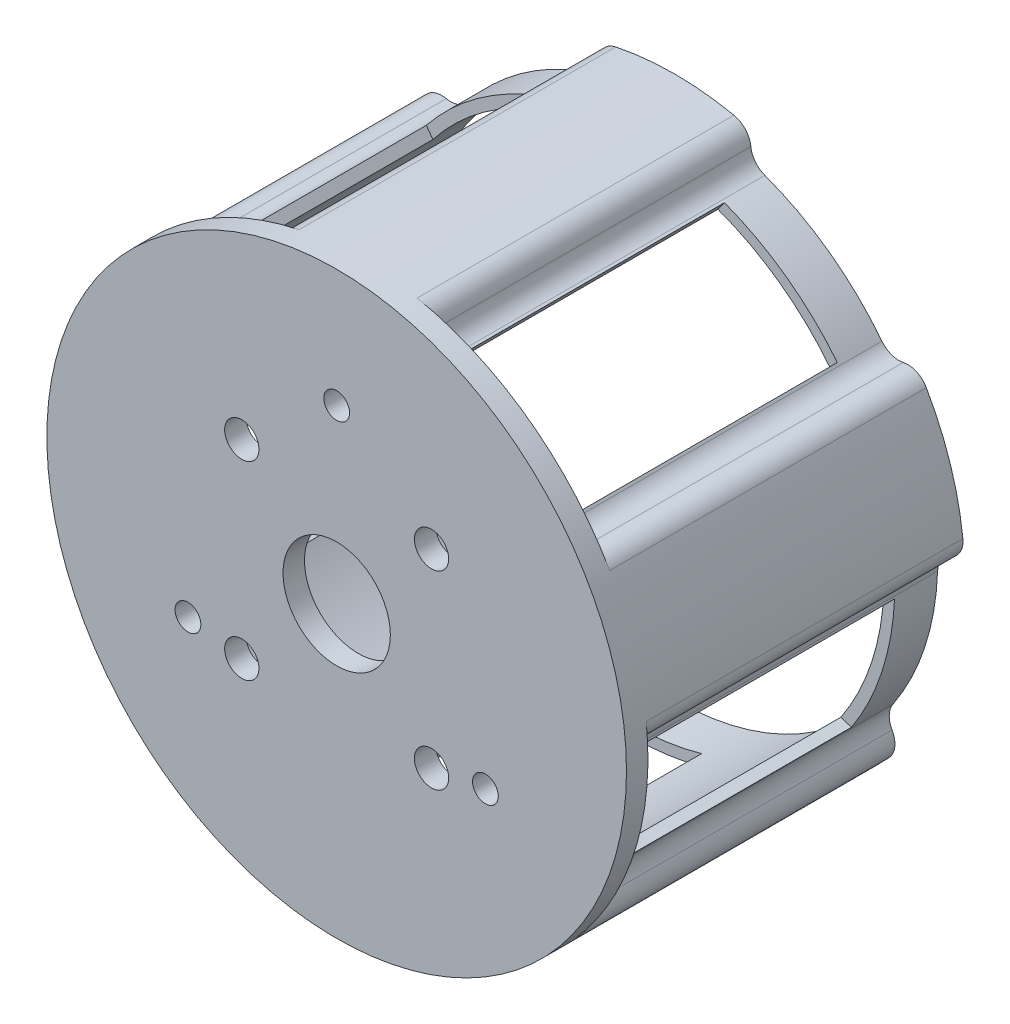
from build123d import *

# Parameters (mm, degrees)
SKETCH_1_R          = 27
SKETCH_1_R_2        = 23.5
SKETCH_1_R_3        = 1
EXTRUDE_1_DEPTH     = 27.5
CUT_EXTRUDE_1_DEPTH = 26
SKETCH_3_R          = 27
SKETCH_3_R_2        = 1.595744681
EXTRUDE_2_DEPTH     = 1.5
SKETCH_4_R          = 5
CUT_EXTRUDE_2_DEPTH = 1.5
SKETCH_5_R          = 1.2
CUT_EXTRUDE_3_DEPTH = 1.5
SKETCH_6_R          = 27
SKETCH_6_R_2        = 23.5
SKETCH_6_R_3        = 1
EXTRUDE_3_DEPTH     = 2
SKETCH_7_R          = 27
SKETCH_7_R_2        = 1.2
SKETCH_7_R_3        = 1.595744681
SKETCH_7_R_4        = 5
EXTRUDE_4_DEPTH     = 0.5
FILLET_1_R          = 1
FILLET_2_R          = 1
FILLET_3_R          = 1
CUT_EXTRUDE_4_DEPTH = 0.8
FILLET_4_R          = 1
CUT_EXTRUDE_5_DEPTH = 29.5
FILLET_5_R          = 2
SKETCH_10_R         = 23.5
SKETCH_10_R_2       = 1
EXTRUDE_6_DEPTH     = 4


with BuildPart() as part:
    # 草图1 → 凸台-拉伸1 (new body)
    with BuildSketch(Plane.XY):
        Circle(SKETCH_1_R)
        Circle(SKETCH_1_R_2, mode=Mode.SUBTRACT)
        with Locations((0, 25)):
            Circle(SKETCH_1_R_3, mode=Mode.SUBTRACT)
        with Locations((23.776412907, 7.725424859)):
            Circle(SKETCH_1_R_3, mode=Mode.SUBTRACT)
        with Locations((14.694631307, -20.225424859)):
            Circle(SKETCH_1_R_3, mode=Mode.SUBTRACT)
        with Locations((-14.694631307, -20.225424859)):
            Circle(SKETCH_1_R_3, mode=Mode.SUBTRACT)
        with Locations((-23.776412907, 7.725424859)):
            Circle(SKETCH_1_R_3, mode=Mode.SUBTRACT)
    extrude(amount=EXTRUDE_1_DEPTH)

    # 草图2 → 切除-拉伸1 (cut)
    with BuildSketch(Plane.XY.offset(27.5)):
        with BuildLine():
            Line((-19.469269636, -13.160453634), (-22.914696108, -14.279940556))
            ThreePointArc((-22.914696108, -14.279940556), (-25.67852594, -8.343458848), (-26.931917035, -1.916205844))
            Line((-26.931917035, -1.916205844), (-23.486490563, -0.796718922))
            ThreePointArc((-23.486490563, -0.796718922), (-22.349828133, -7.261899368), (-19.469269636, -13.160453634))
        make_face()
        with BuildLine():
            Line((6.5, -22.583179581), (6.5, -26.205915363))
            ThreePointArc((6.5, -26.205915363), (0, -27), (-6.5, -26.205915363))
            Line((-6.5, -26.205915363), (-6.5, -22.583179581))
            ThreePointArc((-6.5, -22.583179581), (0, -23.5), (6.5, -22.583179581))
        make_face()
        with BuildLine():
            Line((-18.532670371, 14.449571928), (-20.662061036, 17.380426742))
            ThreePointArc((-20.662061036, 17.380426742), (-15.870201812, 21.843458848), (-10.14484011, 25.021635022))
            Line((-10.14484011, 25.021635022), (-8.015449444, 22.090780208))
            ThreePointArc((-8.015449444, 22.090780208), (-13.812953429, 19.011899368), (-18.532670371, 14.449571928))
        make_face()
        with BuildLine():
            Line((8.015449444, 22.090780208), (10.14484011, 25.021635022))
            ThreePointArc((10.14484011, 25.021635022), (15.870201812, 21.843458848), (20.662061036, 17.380426742))
            Line((20.662061036, 17.380426742), (18.532670371, 14.449571928))
            ThreePointArc((18.532670371, 14.449571928), (13.812953429, 19.011899368), (8.015449444, 22.090780208))
        make_face()
        with BuildLine():
            Line((23.486490563, -0.796718922), (26.931917035, -1.916205844))
            ThreePointArc((26.931917035, -1.916205844), (25.67852594, -8.343458848), (22.914696108, -14.279940556))
            Line((22.914696108, -14.279940556), (19.469269636, -13.160453634))
            ThreePointArc((19.469269636, -13.160453634), (22.349828133, -7.261899368), (23.486490563, -0.796718922))
        make_face()
    extrude(amount=-CUT_EXTRUDE_1_DEPTH, mode=Mode.SUBTRACT)

    # 草图3 → 凸台-拉伸2 (add)
    with BuildSketch(Plane.XY.offset(27.5)):
        Circle(SKETCH_3_R)
        with Locations((8.838834765, 8.838834765)):
            Circle(SKETCH_3_R_2, mode=Mode.SUBTRACT)
        with Locations((-8.838834765, 8.838834765)):
            Circle(SKETCH_3_R_2, mode=Mode.SUBTRACT)
        with Locations((-8.838834765, -8.838834765)):
            Circle(SKETCH_3_R_2, mode=Mode.SUBTRACT)
        with Locations((8.838834765, -8.838834765)):
            Circle(SKETCH_3_R_2, mode=Mode.SUBTRACT)
    extrude(amount=EXTRUDE_2_DEPTH)

    # 草图4 → 切除-拉伸2 (cut)
    with BuildSketch(Plane.XY.offset(29)):
        Circle(SKETCH_4_R)
    extrude(amount=-CUT_EXTRUDE_2_DEPTH, mode=Mode.SUBTRACT)

    # 草图5 → 切除-拉伸3 (cut)
    with BuildSketch(Plane.XY.offset(29)):
        with Locations((0, 16)):
            Circle(SKETCH_5_R)
        with Locations((13.856406461, -8)):
            Circle(SKETCH_5_R)
        with Locations((-13.856406461, -8)):
            Circle(SKETCH_5_R)
    extrude(amount=-CUT_EXTRUDE_3_DEPTH, mode=Mode.SUBTRACT)

    # 草图6 → 凸台-拉伸3 (add)
    with BuildSketch(Plane(origin=(0, 0, 0), x_dir=(-1, 0, 0), z_dir=(0, 0, -1))):
        Circle(SKETCH_6_R)
        Circle(SKETCH_6_R_2, mode=Mode.SUBTRACT)
        with Locations((14.694631307, -20.225424859)):
            Circle(SKETCH_6_R_3, mode=Mode.SUBTRACT)
        with Locations((-14.694631307, -20.225424859)):
            Circle(SKETCH_6_R_3, mode=Mode.SUBTRACT)
        with Locations((-23.776412907, 7.725424859)):
            Circle(SKETCH_6_R_3, mode=Mode.SUBTRACT)
        with Locations((0, 25)):
            Circle(SKETCH_6_R_3, mode=Mode.SUBTRACT)
        with Locations((23.776412907, 7.725424859)):
            Circle(SKETCH_6_R_3, mode=Mode.SUBTRACT)
    extrude(amount=EXTRUDE_3_DEPTH)

    # 草图7 → 凸台-拉伸4 (add)
    with BuildSketch(Plane.XY.offset(29)):
        Circle(SKETCH_7_R)
        with Locations((0, 16)):
            Circle(SKETCH_7_R_2, mode=Mode.SUBTRACT)
        with Locations((-8.838834765, 8.838834765)):
            Circle(SKETCH_7_R_3, mode=Mode.SUBTRACT)
        with Locations((-13.856406461, -8)):
            Circle(SKETCH_7_R_2, mode=Mode.SUBTRACT)
        with Locations((-8.838834765, -8.838834765)):
            Circle(SKETCH_7_R_3, mode=Mode.SUBTRACT)
        with Locations((13.856406461, -8)):
            Circle(SKETCH_7_R_2, mode=Mode.SUBTRACT)
        with Locations((8.838834765, -8.838834765)):
            Circle(SKETCH_7_R_3, mode=Mode.SUBTRACT)
        Circle(SKETCH_7_R_4, mode=Mode.SUBTRACT)
        with Locations((8.838834765, 8.838834765)):
            Circle(SKETCH_7_R_3, mode=Mode.SUBTRACT)
    extrude(amount=EXTRUDE_4_DEPTH)

    # 圆角1
    fillet_1_edges = [part.edges().sort_by_distance(p)[0] for p in [
        (-21.191982872, -13.720197095, 27.5),
    ]]
    fillet(fillet_1_edges, radius=FILLET_1_R)

    # 圆角2
    fillet_2_edges = [part.edges().sort_by_distance(p)[0] for p in [
        (-25.209203799, -1.356462383, 27.5),
    ]]
    fillet(fillet_2_edges, radius=FILLET_2_R)

    # 圆角3
    fillet_3_edges = [part.edges().sort_by_distance(p)[0] for p in [
        (6.5, -24.394547472, 27.5),
        (-6.5, -24.394547472, 27.5),
        (-19.597365704, 15.914999335, 27.5),
        (-9.080144777, 23.556207615, 27.5),
        (9.080144777, 23.556207615, 27.5),
        (19.597365704, 15.914999335, 27.5),
        (25.209203799, -1.356462383, 27.5),
        (21.191982872, -13.720197095, 27.5),
    ]]
    fillet(fillet_3_edges, radius=FILLET_3_R)

    # 草图8 → 切除-拉伸4 (cut)
    with BuildSketch(Plane.XY.offset(1.5)):
        with BuildLine():
            Line((19.469269636, -13.160453634), (22.914696108, -14.279940556))
            ThreePointArc((22.914696108, -14.279940556), (25.67852594, -8.343458848), (26.931917035, -1.916205844))
            Line((26.931917035, -1.916205844), (23.486490563, -0.796718922))
            ThreePointArc((23.486490563, -0.796718922), (22.349828133, -7.261899368), (19.469269636, -13.160453634))
        make_face()
        with BuildLine():
            Line((10.14484011, 25.021635022), (8.015449444, 22.090780208))
            ThreePointArc((8.015449444, 22.090780208), (13.812953429, 19.011899368), (18.532670371, 14.449571928))
            Line((18.532670371, 14.449571928), (20.662061036, 17.380426742))
            ThreePointArc((20.662061036, 17.380426742), (15.870201812, 21.843458848), (10.14484011, 25.021635022))
        make_face()
        with BuildLine():
            Line((-6.5, -22.583179581), (-6.5, -26.205915363))
            ThreePointArc((-6.5, -26.205915363), (0, -27), (6.5, -26.205915363))
            Line((6.5, -26.205915363), (6.5, -22.583179581))
            ThreePointArc((6.5, -22.583179581), (0, -23.5), (-6.5, -22.583179581))
        make_face()
        with BuildLine():
            Line((-23.486490563, -0.796718922), (-26.931917035, -1.916205844))
            ThreePointArc((-26.931917035, -1.916205844), (-25.67852594, -8.343458848), (-22.914696108, -14.279940556))
            Line((-22.914696108, -14.279940556), (-19.469269636, -13.160453634))
            ThreePointArc((-19.469269636, -13.160453634), (-22.349828133, -7.261899368), (-23.486490563, -0.796718922))
        make_face()
        with BuildLine():
            Line((-8.015449444, 22.090780208), (-10.14484011, 25.021635022))
            ThreePointArc((-10.14484011, 25.021635022), (-15.870201812, 21.843458848), (-20.662061036, 17.380426742))
            Line((-20.662061036, 17.380426742), (-18.532670371, 14.449571928))
            ThreePointArc((-18.532670371, 14.449571928), (-13.812953429, 19.011899368), (-8.015449444, 22.090780208))
        make_face()
    extrude(amount=-CUT_EXTRUDE_4_DEPTH, mode=Mode.SUBTRACT)

    # 圆角4
    fillet_4_edges = [part.edges().sort_by_distance(p)[0] for p in [
        (-9.080144777, 23.556207615, 0.7),
        (-19.597365704, 15.914999335, 0.7),
        (-25.209203799, -1.356462383, 0.7),
        (-21.191982872, -13.720197095, 0.7),
        (-6.5, -24.394547472, 0.7),
        (6.5, -24.394547472, 0.7),
        (21.191982872, -13.720197095, 0.7),
        (25.209203799, -1.356462383, 0.7),
        (19.597365704, 15.914999335, 0.7),
        (9.080144777, 23.556207615, 0.7),
    ]]
    fillet(fillet_4_edges, radius=FILLET_4_R)

    # 草图9 → 切除-拉伸5 (cut)
    with BuildSketch(Plane(origin=(0, 0, -2), x_dir=(-1, 0, 0), z_dir=(0, 0, -1))):
        with BuildLine():
            Line((21.153306776, 14.336583011), (20.083521571, 14.032183056))
            ThreePointArc((20.083521571, 14.032183056), (14.929861697, 19.42547888), (8.392087366, 23.01788152))
            ThreePointArc((8.392087366, 23.01788152), (7.501479868, 23.665127017), (7.088344874, 24.685630779))
            ThreePointArc((7.088344874, 24.685630779), (6.582389612, 25.816434618), (5.507496749, 26.432318846))
            ThreePointArc((5.507496749, 26.432318846), (15.870201812, 21.843458848), (23.436718987, 13.405976395))
            ThreePointArc((23.436718987, 13.405976395), (22.455487368, 14.265032976), (21.153306776, 14.336583011))
        make_face()
        with BuildLine():
            ThreePointArc((-11.080868735, -24.621420513), (-9.849254476, -24.754965879), (-8.77525825, -24.137519397))
            ThreePointArc((-8.77525825, -24.137519397), (-7.841187958, -23.554749168), (-6.740229999, -23.554602513))
            ThreePointArc((-6.740229999, -23.554602513), (0, -24.5), (6.740229999, -23.554602513))
            ThreePointArc((6.740229999, -23.554602513), (7.841187958, -23.554749168), (8.77525825, -24.137519397))
            ThreePointArc((8.77525825, -24.137519397), (9.849254476, -24.754965879), (11.080868735, -24.621420513))
            ThreePointArc((11.080868735, -24.621420513), (0, -27), (-11.080868735, -24.621420513))
        make_face()
        with BuildLine():
            ThreePointArc((19.992185667, -18.146969781), (20.499784595, -17.016902801), (20.244441181, -15.804670237))
            ThreePointArc((20.244441181, -15.804670237), (19.97883735, -14.736230695), (20.318912593, -13.689112134))
            ThreePointArc((20.318912593, -13.689112134), (23.300884649, -7.570916362), (24.484603825, -0.86843281))
            ThreePointArc((24.484603825, -0.86843281), (24.824958021, 0.178595112), (25.667849039, 0.886862845))
            ThreePointArc((25.667849039, 0.886862845), (26.586958624, 1.717492498), (26.840539171, 2.930095053))
            ThreePointArc((26.840539171, 2.930095053), (25.67852594, -8.343458848), (19.992185667, -18.146969781))
        make_face()
        with BuildLine():
            ThreePointArc((-5.507496749, 26.432318846), (-6.582389612, 25.816434618), (-7.088344874, 24.685630779))
            ThreePointArc((-7.088344874, 24.685630779), (-7.501479868, 23.665127017), (-8.392087366, 23.01788152))
            ThreePointArc((-8.392087366, 23.01788152), (-14.400738681, 19.820916362), (-19.298008596, 15.094265938))
            ThreePointArc((-19.298008596, 15.094265938), (-20.188788497, 14.447257733), (-21.287010983, 14.36969601))
            ThreePointArc((-21.287010983, 14.36969601), (-22.518818117, 14.237941564), (-23.436718987, 13.405976395))
            ThreePointArc((-23.436718987, 13.405976395), (-15.870201812, 21.843458848), (-5.507496749, 26.432318846))
        make_face()
        with BuildLine():
            ThreePointArc((-26.840539171, 2.930095053), (-26.586958624, 1.717492498), (-25.667849039, 0.886862845))
            ThreePointArc((-25.667849039, 0.886862845), (-24.824958021, 0.178595112), (-24.484603825, -0.86843281))
            ThreePointArc((-24.484603825, -0.86843281), (-23.300884649, -7.570916362), (-20.318912593, -13.689112134))
            ThreePointArc((-20.318912593, -13.689112134), (-19.97883735, -14.736230694), (-20.244441181, -15.804670237))
            ThreePointArc((-20.244441181, -15.804670237), (-20.499784595, -17.016902801), (-19.992185667, -18.146969781))
            ThreePointArc((-19.992185667, -18.146969781), (-25.67852594, -8.343458848), (-26.840539171, 2.930095053))
        make_face()
    extrude(amount=-CUT_EXTRUDE_5_DEPTH, mode=Mode.SUBTRACT)

    # 圆角5
    fillet_5_edges = [part.edges().sort_by_distance(p)[0] for p in [
        (-20.083521571, 14.032183056, 12.75),
    ]]
    fillet(fillet_5_edges, radius=FILLET_5_R)

    # 草图10 → 凸台-拉伸6 (add)
    with BuildSketch(Plane(origin=(0, 0, -2), x_dir=(-1, 0, 0), z_dir=(0, 0, -1))):
        with BuildLine():
            ThreePointArc((-21.287010983, 14.36969601), (-22.518818117, 14.237941564), (-23.436718987, 13.405976395))
            ThreePointArc((-23.436718987, 13.405976395), (-25.67852594, 8.343458848), (-26.840539171, 2.930095053))
            ThreePointArc((-26.840539171, 2.930095053), (-26.586958624, 1.717492498), (-25.667849039, 0.886862845))
            ThreePointArc((-25.667849039, 0.886862845), (-24.824958021, 0.178595112), (-24.484603825, -0.86843281))
            ThreePointArc((-24.484603825, -0.86843281), (-23.300884649, -7.570916362), (-20.318912593, -13.689112134))
            ThreePointArc((-20.318912593, -13.689112134), (-19.97883735, -14.736230694), (-20.244441181, -15.804670237))
            ThreePointArc((-20.244441181, -15.804670237), (-20.499784595, -17.016902801), (-19.992185667, -18.146969781))
            ThreePointArc((-19.992185667, -18.146969781), (-15.870201812, -21.843458848), (-11.080868735, -24.621420513))
            ThreePointArc((-11.080868735, -24.621420513), (-9.849254476, -24.754965879), (-8.77525825, -24.137519397))
            ThreePointArc((-8.77525825, -24.137519397), (-7.841187958, -23.554749168), (-6.740229999, -23.554602513))
            ThreePointArc((-6.740229999, -23.554602513), (0, -24.5), (6.740229999, -23.554602513))
            ThreePointArc((6.740229999, -23.554602513), (7.841187958, -23.554749168), (8.77525825, -24.137519397))
            ThreePointArc((8.77525825, -24.137519397), (9.849254476, -24.754965879), (11.080868735, -24.621420513))
            ThreePointArc((11.080868735, -24.621420513), (15.870201812, -21.843458848), (19.992185667, -18.146969781))
            ThreePointArc((19.992185667, -18.146969781), (20.499784595, -17.016902801), (20.244441181, -15.804670237))
            ThreePointArc((20.244441181, -15.804670237), (19.97883735, -14.736230695), (20.318912593, -13.689112134))
            ThreePointArc((20.318912593, -13.689112134), (23.300884649, -7.570916362), (24.484603825, -0.86843281))
            ThreePointArc((24.484603825, -0.86843281), (24.824958021, 0.178595112), (25.667849039, 0.886862845))
            ThreePointArc((25.667849039, 0.886862845), (26.586958624, 1.717492498), (26.840539171, 2.930095053))
            ThreePointArc((26.840539171, 2.930095053), (25.67852594, 8.343458848), (23.436718987, 13.405976395))
            ThreePointArc((23.436718987, 13.405976395), (22.518818117, 14.237941564), (21.287010983, 14.36969601))
            ThreePointArc((21.287010983, 14.36969601), (20.188788497, 14.447257733), (19.298008596, 15.094265938))
            ThreePointArc((19.298008596, 15.094265938), (14.400738681, 19.820916362), (8.392087366, 23.01788152))
            ThreePointArc((8.392087366, 23.01788152), (7.501479868, 23.665127017), (7.088344874, 24.685630779))
            ThreePointArc((7.088344874, 24.685630779), (6.582389612, 25.816434618), (5.507496749, 26.432318846))
            ThreePointArc((5.507496749, 26.432318846), (0, 27), (-5.507496749, 26.432318846))
            ThreePointArc((-5.507496749, 26.432318846), (-6.582389612, 25.816434618), (-7.088344874, 24.685630779))
            ThreePointArc((-7.088344874, 24.685630779), (-7.501479868, 23.665127017), (-8.392087366, 23.01788152))
            ThreePointArc((-8.392087366, 23.01788152), (-14.400738681, 19.820916362), (-19.298008596, 15.094265938))
            ThreePointArc((-19.298008596, 15.094265938), (-20.188788497, 14.447257733), (-21.287010983, 14.36969601))
        make_face()
        Circle(SKETCH_10_R, mode=Mode.SUBTRACT)
        with Locations((-14.694631307, -20.225424859)):
            Circle(SKETCH_10_R_2, mode=Mode.SUBTRACT)
        with Locations((-23.776412907, 7.725424859)):
            Circle(SKETCH_10_R_2, mode=Mode.SUBTRACT)
        with Locations((0, 25)):
            Circle(SKETCH_10_R_2, mode=Mode.SUBTRACT)
        with Locations((23.776412907, 7.725424859)):
            Circle(SKETCH_10_R_2, mode=Mode.SUBTRACT)
        with Locations((14.694631307, -20.225424859)):
            Circle(SKETCH_10_R_2, mode=Mode.SUBTRACT)
    extrude(amount=-EXTRUDE_6_DEPTH)


solid = part.part
